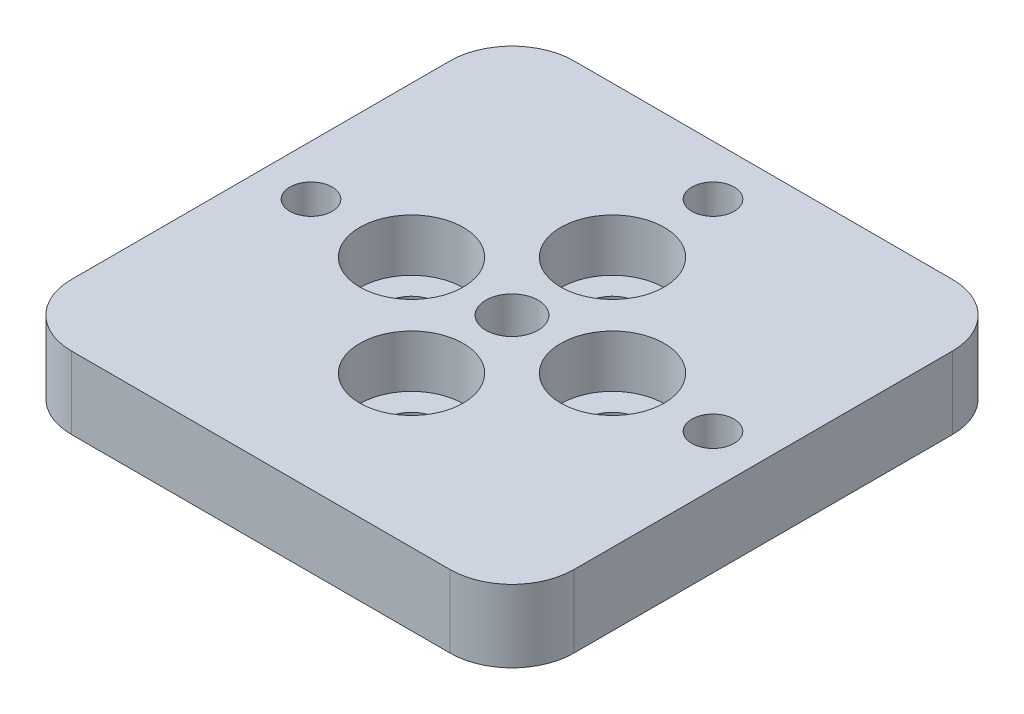
from build123d import *

# Parameters (mm, degrees)
SKETCH_2_W          = 50
SKETCH_2_H          = 50
SKETCH_2_R          = 2.6
EXTRUDE_1_DEPTH     = 2
SKETCH_3_W          = 50
SKETCH_3_H          = 50
SKETCH_3_R          = 5.15
SKETCH_3_R_2        = 2.6
EXTRUDE_2_DEPTH     = 5.2
SKETCH_4_R          = 2.1
CUT_EXTRUDE_1_DEPTH = 10
CUT_EXTRUDE_2_DEPTH = 3.5
FILLET_1_R          = 6.17
FILLET_2_R          = 6.17
FILLET_3_R          = 6.17
FILLET_4_R          = 6.17


with BuildPart() as part:
    # 스케치2 → 보스-돌출1 (new body)
    with BuildSketch(Plane(origin=(0, 0, 0), x_dir=(1, 0, 0), z_dir=(0, 1, 0))):
        Rectangle(SKETCH_2_W, SKETCH_2_H)
        Circle(SKETCH_2_R, mode=Mode.SUBTRACT)
        with Locations((10, 0)):
            Circle(SKETCH_2_R, mode=Mode.SUBTRACT)
        with Locations((0, -10)):
            Circle(SKETCH_2_R, mode=Mode.SUBTRACT)
        with Locations((-10, 0)):
            Circle(SKETCH_2_R, mode=Mode.SUBTRACT)
        with Locations((0, 10)):
            Circle(SKETCH_2_R, mode=Mode.SUBTRACT)
    extrude(amount=EXTRUDE_1_DEPTH)

    # 스케치3 → 보스-돌출2 (add)
    with BuildSketch(Plane(origin=(0, 2, 0), x_dir=(1, 0, 0), z_dir=(0, 1, 0))):
        Rectangle(SKETCH_3_W, SKETCH_3_H)
        with Locations((0, -10)):
            Circle(SKETCH_3_R, mode=Mode.SUBTRACT)
        with Locations((-10, 0)):
            Circle(SKETCH_3_R, mode=Mode.SUBTRACT)
        Circle(SKETCH_3_R_2, mode=Mode.SUBTRACT)
        with Locations((10, 0)):
            Circle(SKETCH_3_R, mode=Mode.SUBTRACT)
        with Locations((0, 10)):
            Circle(SKETCH_3_R, mode=Mode.SUBTRACT)
    extrude(amount=EXTRUDE_2_DEPTH)

    # 스케치4 → 컷-돌출1 (cut)
    with BuildSketch(Plane(origin=(0, 7.2, 0), x_dir=(1, 0, 0), z_dir=(0, 1, 0))):
        with Locations((20, 0)):
            Circle(SKETCH_4_R)
        with Locations((0, 20)):
            Circle(SKETCH_4_R)
        with Locations((-20, 0)):
            Circle(SKETCH_4_R)
    extrude(amount=-CUT_EXTRUDE_1_DEPTH, mode=Mode.SUBTRACT)

    # 스케치6 → 컷-돌출2 (cut)
    with BuildSketch(Plane.XZ):
        Polygon((-16.45, -2.049593456), (-16.45, 2.049593456), (-20, 4.099186911), (-23.55, 2.049593456), (-23.55, -2.049593456), (-20, -4.099186911), align=None)
        Polygon((2.049593456, -16.45), (-2.049593456, -16.45), (-4.099186911, -20), (-2.049593456, -23.55), (2.049593456, -23.55), (4.099186911, -20), align=None)
        Polygon((16.45, 2.049593456), (16.45, -2.049593456), (20, -4.099186911), (23.55, -2.049593456), (23.55, 2.049593456), (20, 4.099186911), align=None)
    extrude(amount=-CUT_EXTRUDE_2_DEPTH, mode=Mode.SUBTRACT)

    # 필렛1
    fillet_1_edges = [part.edges().sort_by_distance(p)[0] for p in [
        (25, 3.6, -25),
    ]]
    fillet(fillet_1_edges, radius=FILLET_1_R)

    # 필렛2
    fillet_2_edges = [part.edges().sort_by_distance(p)[0] for p in [
        (25, 3.6, 25),
    ]]
    fillet(fillet_2_edges, radius=FILLET_2_R)

    # 필렛3
    fillet_3_edges = [part.edges().sort_by_distance(p)[0] for p in [
        (-25, 3.6, 25),
    ]]
    fillet(fillet_3_edges, radius=FILLET_3_R)

    # 필렛4
    fillet_4_edges = [part.edges().sort_by_distance(p)[0] for p in [
        (-25, 3.6, -25),
    ]]
    fillet(fillet_4_edges, radius=FILLET_4_R)


solid = part.part
